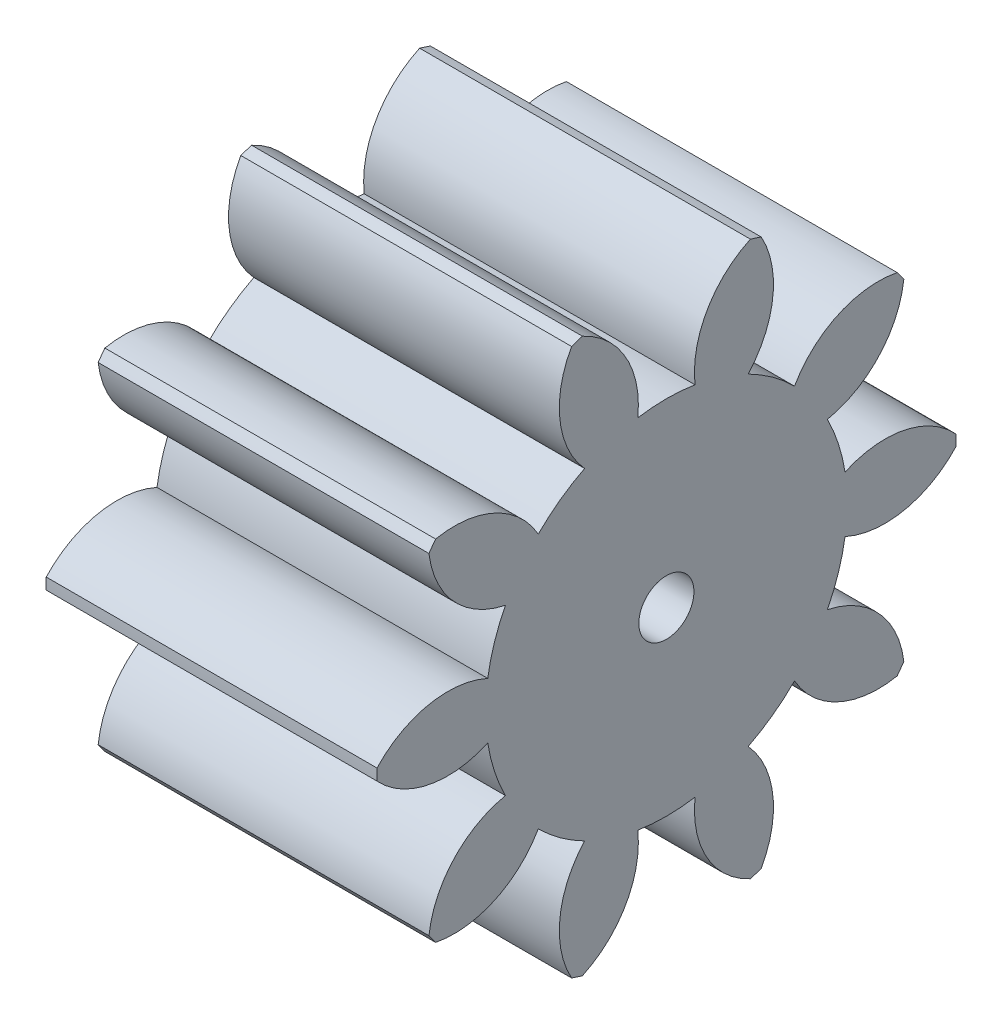
from build123d import *

# Parameters (mm, degrees)
BASPROSKE_W     = 4.8
BASPROSKE_H     = 4.2
TOOTHCUT_DEPTH  = 8.636753237
TEETHCUTS_COUNT = 10
TEETHCUTS_ANGLE = 324
BORSKE_R        = 0.4
BORE_DEPTH      = 50.0000508


with BuildPart() as part:
    # BasProSke → Base-Revolve (revolve)
    with BuildSketch(Plane(origin=(0, 0, 0), x_dir=(1, 0, 0), z_dir=(0, 1, 0)), mode=Mode.PRIVATE) as base_revolve_sk:
        with Locations((2.4, 2.1)):
            Rectangle(BASPROSKE_W, BASPROSKE_H)
    revolve(base_revolve_sk.sketch.rotate(Axis((-10, 0, 0), (1, 0, 0)), 180), axis=Axis((-10, 0, 0), (1, 0, 0)))

    # TooCutSke → ToothCut (cut, through all)
    with BuildSketch(Plane(origin=(0, 0, 0), x_dir=(0, 0, -1), z_dir=(1, 0, 0))):
        with BuildLine():
            ThreePointArc((0.415506654, 2.590893711), (0, 2.624), (-0.415506654, 2.590893711))
            ThreePointArc((-0.415506654, 2.590893711), (-0.596160737, 3.451685568), (-1.254578949, 4.034852763))
            ThreePointArc((-1.254578949, 4.034852763), (0, 4.2254), (1.254578949, 4.034852763))
            ThreePointArc((1.254578949, 4.034852763), (0.596160737, 3.451685568), (0.415506654, 2.590893711))
        make_face()
    toothcut = extrude(amount=TOOTHCUT_DEPTH, mode=Mode.SUBTRACT)

    # TeethCuts: ToothCut ×10 about axis
    teethcuts_axis = Axis((-10, 0, 0), (1, 0, 0))
    for i in range(1, TEETHCUTS_COUNT):
        add(toothcut.rotate(teethcuts_axis, i * TEETHCUTS_ANGLE / (TEETHCUTS_COUNT - 1)), mode=Mode.SUBTRACT)

    # BorSke → Bore (cut, symmetric)
    with BuildSketch(Plane(origin=(0, 0, 0), x_dir=(0, 0, -1), z_dir=(1, 0, 0))):
        with Locations(Location((0, 0, 0), (0, 0, 180))):
            Circle(BORSKE_R)
    extrude(amount=BORE_DEPTH, both=True, mode=Mode.SUBTRACT)


solid = part.part
